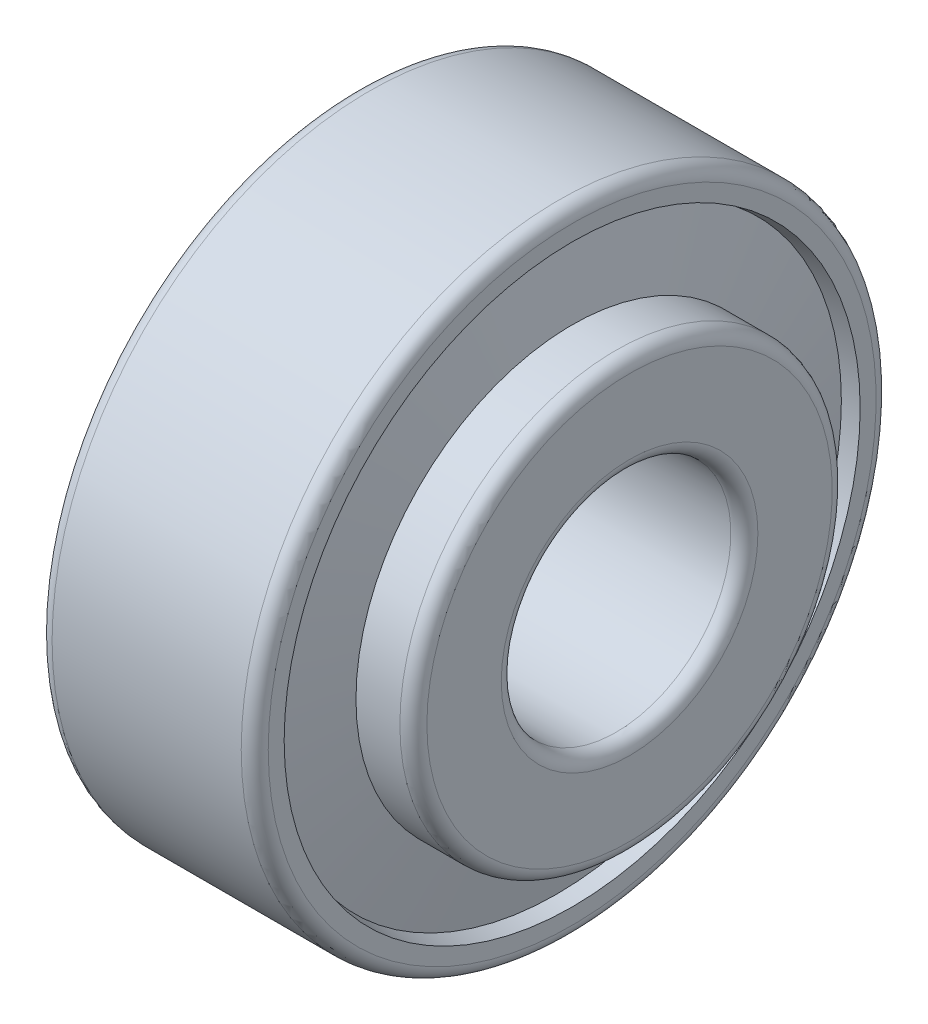
from build123d import *


with BuildPart() as part:
    # Эскиз1 → Повернуть1 (revolve)
    with BuildSketch(Plane.XY):
        with BuildLine():
            Line((2.337367885, 18.523577661), (0, 18.045))
            Line((0, 18.045), (0, 22.5))
            ThreePointArc((0, 22.5), (0.292893219, 23.207106781), (1, 23.5))
            Line((1, 23.5), (15, 23.5))
            ThreePointArc((15, 23.5), (15.707106781, 23.207106781), (16, 22.5))
            Line((16, 22.5), (16, 21.321010862))
            Line((16, 21.321010862), (14.844973298, 21.084518361))
            Line((14.844973298, 21.084518361), (16, 15.005481639))
            Line((16, 15.005481639), (16, 16.005481639))
            Line((16, 16.005481639), (19.25, 16.005481639))
            ThreePointArc((19.25, 16.005481639), (19.957106781, 15.71258842), (20.25, 15.005481639))
            Line((20.25, 15.005481639), (20.25, 9.5))
            ThreePointArc((20.25, 9.5), (19.957106781, 8.792893219), (19.25, 8.5))
            Line((19.25, 8.5), (2.25, 8.5))
            ThreePointArc((2.25, 8.5), (1.542893219, 8.792893219), (1.25, 9.5))
            Line((1.25, 9.5), (1.25, 12.800636979))
            Line((1.25, 12.800636979), (3.42473577, 12.800636979))
            Line((3.42473577, 12.800636979), (2.337367885, 18.523577661))
        make_face()
    revolve(axis=Axis((-882.527700014, 0, 0), (1, 0, 0)))


solid = part.part
